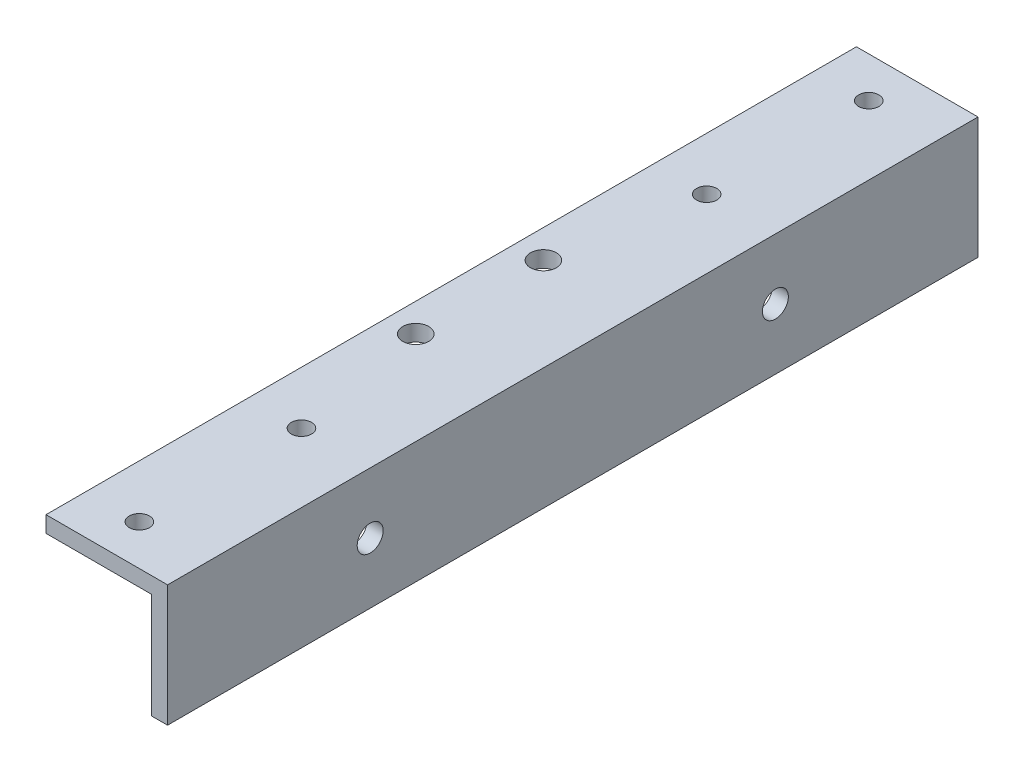
from build123d import *

# Parameters (mm, degrees)
EXTRUDE_1_DEPTH     = 100
SKETCH_4_R          = 1.6
CUT_EXTRUDE_3_DEPTH = 2
M3X0_5_1_D          = 2.5
M3X0_5_1_DEPTH      = 8.5
M3X0_5_1_TIP        = 0.751075774
SKETCH_2_R          = 1.6
CUT_EXTRUDE_4_DEPTH = 10


with BuildPart() as part:
    # ｽｹｯﾁ1 → ﾎﾞｽ - 押し出し1 (new body)
    with BuildSketch(Plane.XY):
        Polygon((0, 0), (15, 0), (15, -15), (13, -15), (13, -2), (0, -2), align=None)
    extrude(amount=EXTRUDE_1_DEPTH)

    # ｽｹｯﾁ4 → ｶｯﾄ - 押し出し3 (cut)
    with BuildSketch(Plane(origin=(0, 0, 0), x_dir=(1, 0, 0), z_dir=(0, 1, 0))):
        with Locations((3.5, -57.875)):
            Circle(SKETCH_4_R)
        with Locations((3.5, -42.125)):
            Circle(SKETCH_4_R)
    extrude(amount=-CUT_EXTRUDE_3_DEPTH, mode=Mode.SUBTRACT)

    # M3x0.5 ねじ穴1
    with Locations(Plane(origin=(6.52, 0, 75), x_dir=(0, 0, 1), z_dir=(0, 1, 0))):
        with Locations((0, 0), (-50, 0), (20, 0), (-70, 0)):
            Hole(M3X0_5_1_D / 2, depth=M3X0_5_1_DEPTH)
            with Locations((0, 0, -(M3X0_5_1_DEPTH + M3X0_5_1_TIP / 2))):  # 118° drill point
                Cone(0, M3X0_5_1_D / 2, M3X0_5_1_TIP, mode=Mode.SUBTRACT)

    # ｽｹｯﾁ2 → ｶｯﾄ - 押し出し4 (cut)
    with BuildSketch(Plane(origin=(15, 0, 0), x_dir=(0, 0, -1), z_dir=(1, 0, 0))):
        with Locations((-75, -7.5)):
            Circle(SKETCH_2_R)
        with Locations((-25, -7.5)):
            Circle(SKETCH_2_R)
    extrude(amount=-CUT_EXTRUDE_4_DEPTH, mode=Mode.SUBTRACT)


solid = part.part
